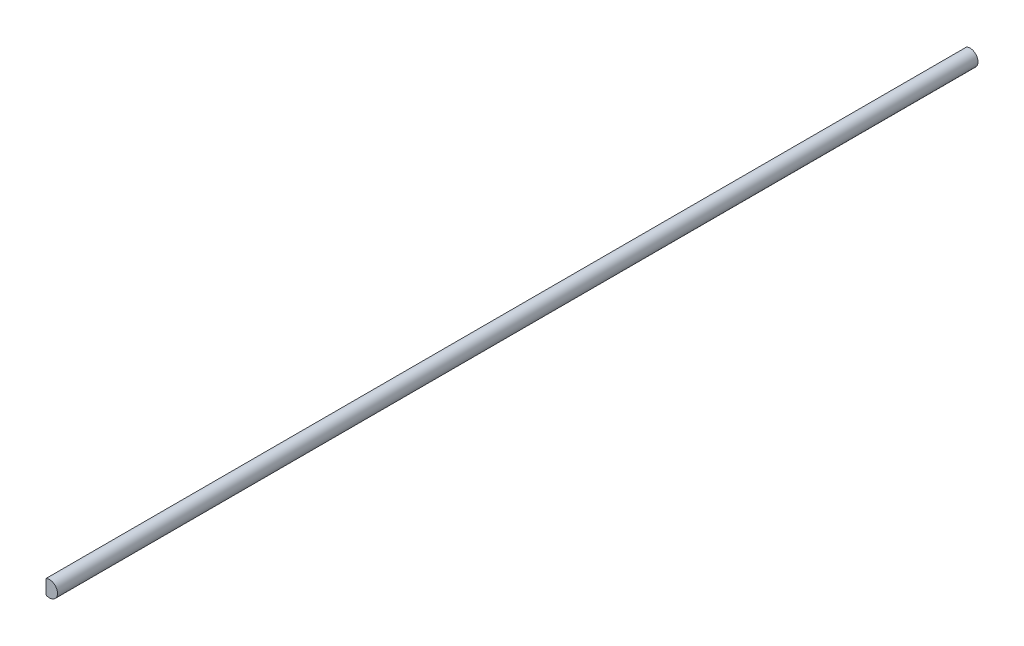
from build123d import *

# Parameters (mm, degrees)
BOSS_EXTRUDE1_DEPTH = 130


with BuildPart() as part:
    # Sketch1 → Boss-Extrude1 (new body, symmetric)
    with BuildSketch(Plane.XY):
        with BuildLine():
            Line((-0.99, 2.020494989), (-0.99, -2.020494989))
            ThreePointArc((-0.99, -2.020494989), (2.25, 0), (-0.99, 2.020494989))
        make_face()
    extrude(amount=BOSS_EXTRUDE1_DEPTH, both=True)


solid = part.part
